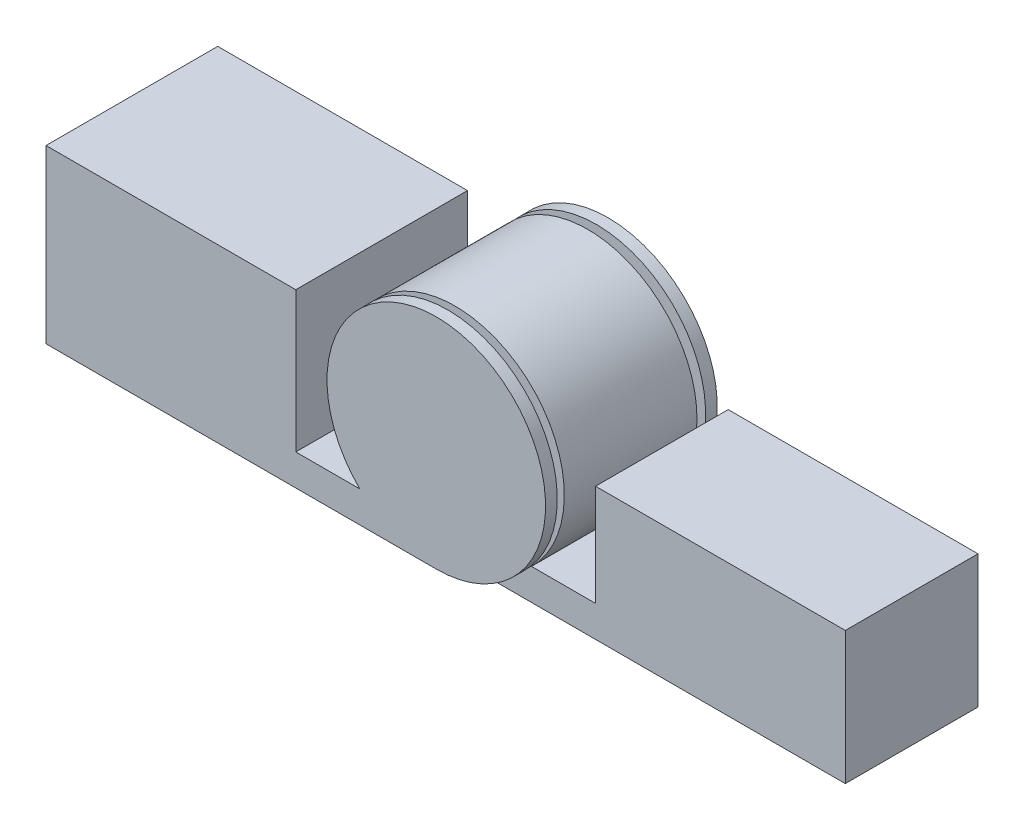
from build123d import *

# Parameters (mm, degrees)
BOSS_EXTRUDE1_DEPTH     = 139.7
SKETCH3_R               = 88.9
CUT_EXTRUDE1_DEPTH      = 60.325
CUT_EXTRUDE1_DEPTH_BACK = 60.325
BOSS_EXTRUDE2_START     = 16.51
BOSS_EXTRUDE2_DEPTH     = 107.95


with BuildPart() as part:
    # Sketch1 → Boss-Extrude1 (new body)
    with BuildSketch(Plane.XY):
        with BuildLine():
            Line((203.2, 0), (317.5, 0))
            ThreePointArc((317.5, 0), (351.101041651, 171.20540687), (255.282960533, 25.4))
            Line((255.282960533, 25.4), (203.2, 25.4))
            Line((203.2, 25.4), (203.2, 139.7))
            Line((203.2, 139.7), (0, 139.7))
            Line((0, 139.7), (0, 0))
            Line((0, 0), (203.2, 0))
        make_face()
    extrude(amount=BOSS_EXTRUDE1_DEPTH)

    # Sketch3 → Cut-Extrude1 (cut, two sides)
    with BuildSketch(Plane.XY.offset(69.85)) as cut_extrude1_sk:
        with Locations((317.5, 88.9)):
            Circle(SKETCH3_R)
    extrude(amount=CUT_EXTRUDE1_DEPTH, mode=Mode.SUBTRACT)
    extrude(cut_extrude1_sk.sketch, amount=-CUT_EXTRUDE1_DEPTH_BACK, mode=Mode.SUBTRACT)

    # Sketch2 → Boss-Extrude2 (add)
    with BuildSketch(Plane.XY.offset(BOSS_EXTRUDE2_START)):
        with BuildLine():
            Line((317.5, 0), (431.8, 0))
            Line((431.8, 0), (635, 0))
            Line((635, 0), (635, 107.95))
            Line((635, 107.95), (431.8, 107.95))
            Line((431.8, 107.95), (431.8, 25.4))
            Line((431.8, 25.4), (379.717039467, 25.4))
            ThreePointArc((379.717039467, 25.4), (283.898958349, 171.20540687), (317.5, 0))
        make_face()
    extrude(amount=BOSS_EXTRUDE2_DEPTH)


solid = part.part
